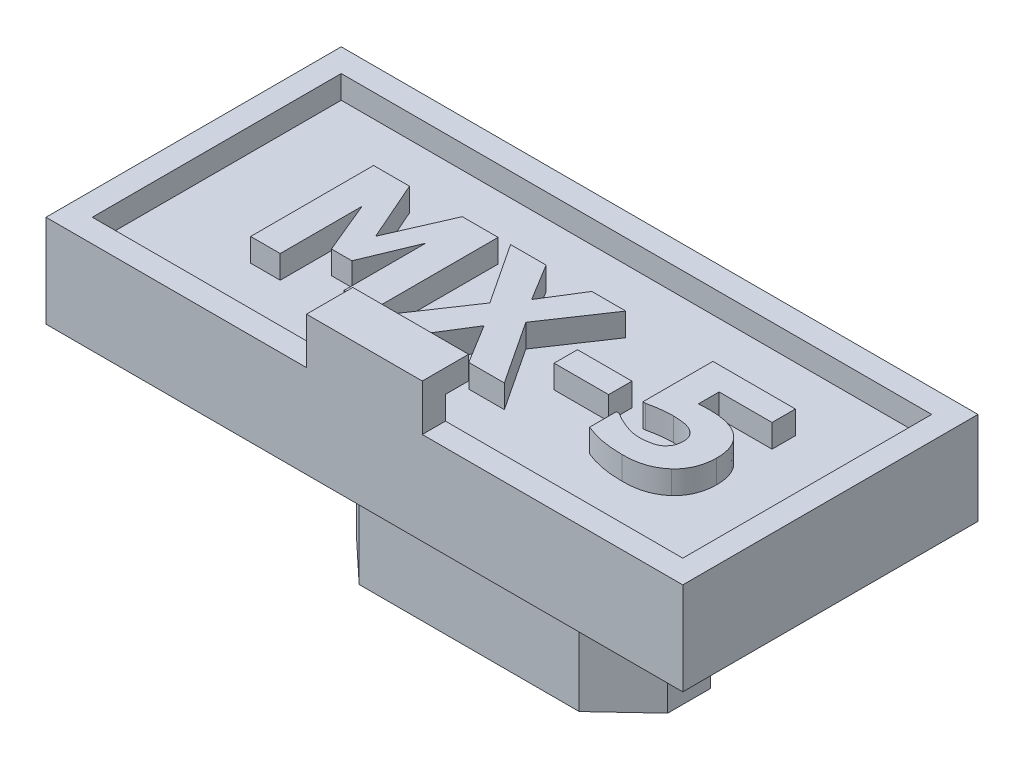
from build123d import *

# Parameters (mm, degrees)
SKETCH1_W           = 13.97
SKETCH1_H           = 6.477
BOSS_EXTRUDE1_DEPTH = 1.524
SKETCH2_W           = 2.54
SKETCH2_H           = 0.508
BOSS_EXTRUDE2_DEPTH = 1.016
SKETCH3_W           = 2.54
SKETCH3_H           = 1.016
BOSS_EXTRUDE3_DEPTH = 0.508
BOSS_EXTRUDE4_DEPTH = 0.508
SKETCH5_W           = 1.195099264
SKETCH5_H           = 0.512185399
BOSS_EXTRUDE5_DEPTH = 0.508
BOSS_EXTRUDE6_DEPTH = 3.81


with BuildPart() as part:
    # Sketch1 → Boss-Extrude1 (new body)
    with BuildSketch(Plane(origin=(0, 0, 0), x_dir=(1, 0, 0), z_dir=(0, 1, 0))):
        Rectangle(SKETCH1_W, SKETCH1_H)
    extrude(amount=BOSS_EXTRUDE1_DEPTH)

    # Sketch2 → Boss-Extrude2 (add)
    with BuildSketch(Plane(origin=(0, 1.524, 0), x_dir=(1, 0, 0), z_dir=(0, 1, 0))):
        with Locations((0, -2.9845)):
            Rectangle(SKETCH2_W, SKETCH2_H)
    extrude(amount=BOSS_EXTRUDE2_DEPTH)

    # Sketch3 → Boss-Extrude3 (add)
    with BuildSketch(Plane(origin=(0, 2.54, 0), x_dir=(1, 0, 0), z_dir=(0, 1, 0))):
        with Locations((0, -2.7305)):
            Rectangle(SKETCH3_W, SKETCH3_H)
    extrude(amount=BOSS_EXTRUDE3_DEPTH)

    # Sketch4 → Boss-Extrude4 (add)
    with BuildSketch(Plane(origin=(0, 1.524, 0), x_dir=(1, 0, 0), z_dir=(0, 1, 0))):
        Polygon((-6.477, -2.7305), (-6.477, 2.7305), (6.477, 2.7305), (6.477, -2.7305), (1.27, -2.7305), (1.27, -3.2385), (6.985, -3.2385), (6.985, 3.2385), (-6.985, 3.2385), (-6.985, -3.2385), (-1.27, -3.2385), (-1.27, -2.7305), align=None)
    extrude(amount=BOSS_EXTRUDE4_DEPTH)

    # Sketch5 → Boss-Extrude5 (add)
    with BuildSketch(Plane(origin=(0, 1.524, 0), x_dir=(1, 0, 0), z_dir=(0, 1, 0))):
        Polygon((-1.643378995, -1.3589), (-2.32629286, -1.3589), (-2.32629286, 0.435883001), (-2.802198459, -0.710131829), (-3.250360683, -0.710131829), (-3.726266283, 0.435883001), (-3.726266283, -1.3589), (-4.375034454, -1.3589), (-4.375034454, 1.338609766), (-3.587549404, 1.338609766), (-3.007606145, 0.016531206), (-2.429796993, 1.338609766), (-1.643378995, 1.338609766), align=None)
        Polygon((1.190713543, -1.3589), (0.410697863, -1.3589), (-0.119093908, -0.495120666), (-0.659022682, -1.3589), (-1.404359143, -1.3589), (-0.488294216, 0.002125991), (-1.370213449, 1.338609766), (-0.590731296, 1.338609766), (-0.094551691, 0.525515445), (0.41123139, 1.338609766), (1.15656785, 1.338609766), (0.274648617, 0.028802314), align=None)
        with Locations((1.958991641, -0.180873583)):
            Rectangle(SKETCH5_W, SKETCH5_H)
        with BuildLine():
            add(Edge.make_bspline(
                [(4.946739799, -0.455106182), (4.94605947, -0.489662616), (4.944721084, -0.557644192), (4.929944432, -0.657573198), (4.908066939, -0.753857587), (4.87622275, -0.845773262), (4.83676263, -0.933299855), (4.786314976, -1.014033908), (4.728286007, -1.089798027), (4.682686747, -1.134274984), (4.659702565, -1.156693473)],
                knots=[0, 0, 0, 0, 0.000103592, 0.000203793, 0.000302407, 0.000399423, 0.000495152, 0.000589768, 0.000684431, 0.000780639, 0.000780639, 0.000780639, 0.000780639], degree=3))
            add(Edge.make_bspline(
                [(4.659702565, -1.156693473), (4.635406854, -1.177518935), (4.586634173, -1.219325227), (4.505001964, -1.272541327), (4.417255575, -1.319210004), (4.321943242, -1.358475376), (4.21766177, -1.389721666), (4.102769549, -1.411786565), (3.976570704, -1.42510693), (3.888613592, -1.426478259), (3.84287356, -1.427191386)],
                knots=[0, 0, 0, 0, 9.5912e-05, 0.000192539, 0.000291587, 0.000393737, 0.000501257, 0.00061761, 0.000744227, 0.000881409, 0.000881409, 0.000881409, 0.000881409], degree=3))
            add(Edge.make_bspline(
                [(3.84287356, -1.427191386), (3.794477078, -1.426480894), (3.700952929, -1.425107899), (3.566044943, -1.41446127), (3.441363909, -1.399893023), (3.327411732, -1.377455404), (3.223622789, -1.351832076), (3.129158438, -1.324471539), (3.044025447, -1.296336264), (2.991260446, -1.274703465), (2.966289592, -1.264465817)],
                knots=[0, 0, 0, 0, 0.000145167, 0.00028053, 0.0004058, 0.000521528, 0.000628671, 0.000726434, 0.000816529, 0.000897473, 0.000897473, 0.000897473, 0.000897473], degree=3))
            Line((2.966289592, -1.264465817), (2.966289592, -0.675986135))
            Line((2.966289592, -0.675986135), (3.028178661, -0.675986135))
            add(Edge.make_bspline(
                [(3.028178661, -0.675986135), (3.0461748, -0.686599796), (3.084373728, -0.709128543), (3.133224942, -0.739286447), (3.177777625, -0.764600081), (3.217135707, -0.784178099), (3.261692934, -0.803718246), (3.292967822, -0.816879929), (3.309347103, -0.823772964)],
                knots=[0, 0, 0, 0, 6.2677e-05, 0.00013304, 0.000172217, 0.000216358, 0.000264842, 0.000318154, 0.000318154, 0.000318154, 0.000318154], degree=3))
            add(Edge.make_bspline(
                [(3.309347103, -0.823772964), (3.34138122, -0.83629162), (3.405232789, -0.861244261), (3.487688702, -0.886196407), (3.555852103, -0.901383164), (3.609882629, -0.909220124), (3.666539884, -0.91414204), (3.705213193, -0.91471392), (3.724964213, -0.915005988)],
                knots=[0, 0, 0, 0, 0.000103158, 0.000205619, 0.000258049, 0.000312526, 0.000369283, 0.000428526, 0.000428526, 0.000428526, 0.000428526], degree=3))
            add(Edge.make_bspline(
                [(3.724964213, -0.915005988), (3.742755847, -0.914663026), (3.779288763, -0.913958795), (3.835093925, -0.909188759), (3.892833649, -0.900129367), (3.951474932, -0.889677579), (4.008759587, -0.875016308), (4.060932423, -0.853514292), (4.107961529, -0.827647814), (4.134493655, -0.805366147), (4.147517167, -0.794429009)],
                knots=[0, 0, 0, 0, 5.3377e-05, 0.000109602, 0.000167852, 0.000228648, 0.00028831, 0.000344784, 0.000397592, 0.000448504, 0.000448504, 0.000448504, 0.000448504], degree=3))
            add(Edge.make_bspline(
                [(4.147517167, -0.794429009), (4.164388109, -0.775955433), (4.197780925, -0.73939051), (4.229692696, -0.685066402), (4.247298267, -0.63645426), (4.257736249, -0.594516462), (4.262394262, -0.546619491), (4.263331382, -0.512910261), (4.263825935, -0.495120666)],
                knots=[0, 0, 0, 0, 7.4941e-05, 0.000148331, 0.000186985, 0.000229817, 0.0002776, 0.000330995, 0.000330995, 0.000330995, 0.000330995], degree=3))
            add(Edge.make_bspline(
                [(4.263825935, -0.495120666), (4.263214375, -0.480167371), (4.262020954, -0.450986903), (4.255637945, -0.408563008), (4.242263097, -0.36988429), (4.225355871, -0.334193666), (4.203453064, -0.30241436), (4.179789927, -0.272527925), (4.151721285, -0.246927559), (4.131136036, -0.232414579), (4.120840844, -0.225156279)],
                knots=[0, 0, 0, 0, 4.4896e-05, 8.7611e-05, 0.000128103, 0.000167236, 0.000205709, 0.000243623, 0.00028138, 0.000319155, 0.000319155, 0.000319155, 0.000319155], degree=3))
            add(Edge.make_bspline(
                [(4.120840844, -0.225156279), (4.104707777, -0.21545969), (4.071734836, -0.195641694), (4.016892486, -0.17391933), (3.957698389, -0.156300514), (3.895021078, -0.146296935), (3.832643779, -0.139181726), (3.773581815, -0.133780992), (3.718958649, -0.130345567), (3.684064997, -0.12987875), (3.667343356, -0.129655044)],
                knots=[0, 0, 0, 0, 5.6382e-05, 0.000115235, 0.000176356, 0.000241352, 0.000305279, 0.000364741, 0.000419255, 0.000469417, 0.000469417, 0.000469417, 0.000469417], degree=3))
            add(Edge.make_bspline(
                [(3.667343356, -0.129655044), (3.617843369, -0.130527073), (3.519806509, -0.132254165), (3.39941227, -0.147583805), (3.307040027, -0.161526065), (3.242965144, -0.173689398), (3.18341676, -0.184924031), (3.145528801, -0.193734262), (3.127414582, -0.19794643)],
                knots=[0, 0, 0, 0, 0.000148416, 0.000293945, 0.000363592, 0.000428682, 0.000489579, 0.000545365, 0.000545365, 0.000545365, 0.000545365], degree=3))
            Line((3.127414582, -0.19794643), (3.068726671, -0.19794643))
            Line((3.068726671, -0.19794643), (3.068726671, 1.338609766))
            Line((3.068726671, 1.338609766), (4.878448413, 1.338609766))
            Line((4.878448413, 1.338609766), (4.878448413, 0.826424367))
            Line((4.878448413, 0.826424367), (3.717494843, 0.826424367))
            Line((3.717494843, 0.826424367), (3.717494843, 0.373460405))
            add(Edge.make_bspline(
                [(3.717494843, 0.373460405), (3.737585525, 0.374808914), (3.780939543, 0.377718884), (3.836285807, 0.379582643), (3.882002433, 0.380815422), (3.913647804, 0.38204891), (3.941040243, 0.382621495), (3.957937284, 0.382558752), (3.965584645, 0.382530355)],
                knots=[0, 0, 0, 0, 6.0404e-05, 0.000130347, 0.000166109, 0.000197605, 0.000225354, 0.000248295, 0.000248295, 0.000248295, 0.000248295], degree=3))
            add(Edge.make_bspline(
                [(3.965584645, 0.382530355), (3.997606389, 0.381939784), (4.060302129, 0.380783498), (4.152627332, 0.374010631), (4.24113585, 0.361615555), (4.326092456, 0.344887486), (4.40663311, 0.322371742), (4.482865869, 0.295381841), (4.554235733, 0.262433225), (4.598396472, 0.235689641), (4.620221608, 0.222472418)],
                knots=[0, 0, 0, 0, 9.6072e-05, 0.0001881, 0.000277512, 0.000364043, 0.000447664, 0.000528163, 0.000606453, 0.000682954, 0.000682954, 0.000682954, 0.000682954], degree=3))
            add(Edge.make_bspline(
                [(4.620221608, 0.222472418), (4.64515183, 0.205211361), (4.6948374, 0.170810326), (4.759231976, 0.10669888), (4.816173661, 0.035295495), (4.863168477, -0.045457051), (4.900760282, -0.134880977), (4.928000594, -0.233413985), (4.943911899, -0.341302226), (4.945775058, -0.416281835), (4.946739799, -0.455106182)],
                knots=[0, 0, 0, 0, 9.0809e-05, 0.000180982, 0.000271389, 0.000364173, 0.000460291, 0.000561647, 0.000670074, 0.000786505, 0.000786505, 0.000786505, 0.000786505], degree=3))
        make_face()
    extrude(amount=BOSS_EXTRUDE5_DEPTH)

    # Sketch6 → Boss-Extrude6 (add)
    with BuildSketch(Plane.XZ):
        Polygon((-3.4163, 0), (-2.413, 0.9398), (2.413, 0.9398), (3.4163, 0), (3.4163, -0.9398), (2.159, -0.9398), (2.159, -0.0762), (-2.159, -0.0762), (-2.159, -0.9398), (-3.4163, -0.9398), align=None)
    extrude(amount=BOSS_EXTRUDE6_DEPTH)


solid = part.part
